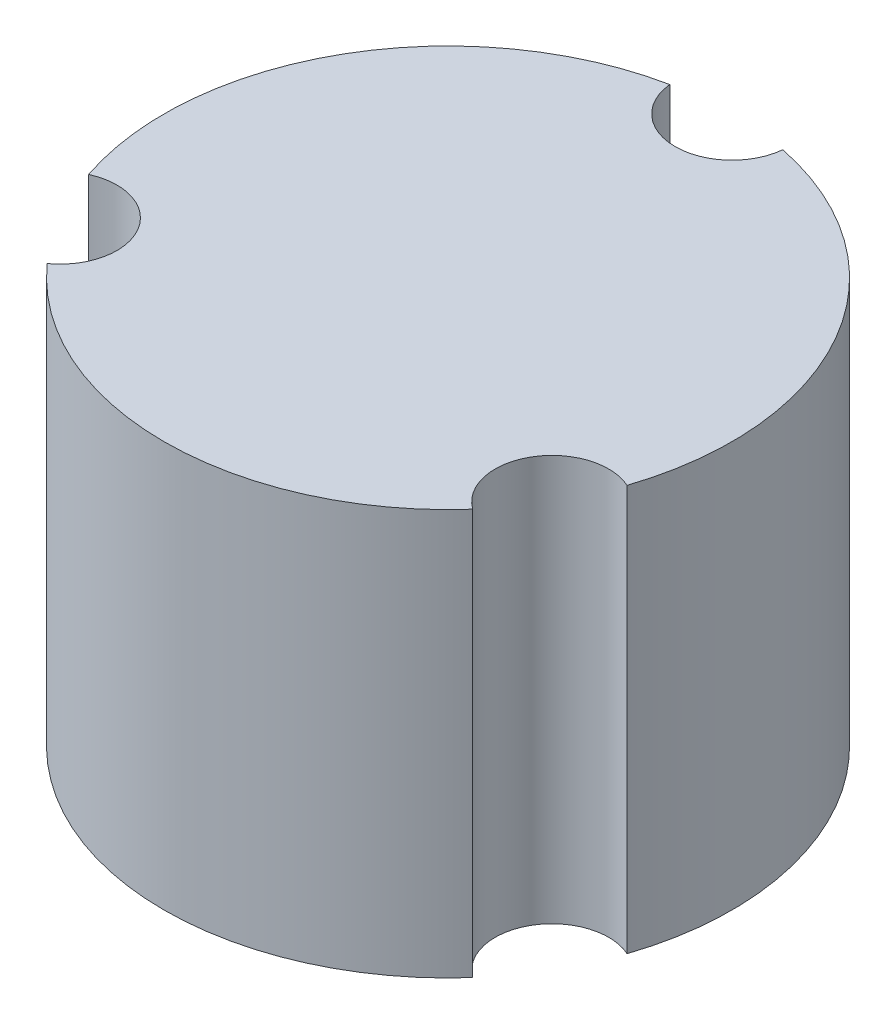
from build123d import *

# Parameters (mm, degrees)
CROQUIS1_R              = 22.225
SALIENTE_EXTRUIR1_DEPTH = 31.75
CROQUIS2_R              = 4.445
CORTAR_EXTRUIR1_DEPTH   = 32.75
VACIADO1_T              = -6.35


with BuildPart() as part:
    # Croquis1 → Saliente-Extruir1 (new body)
    with BuildSketch(Plane(origin=(0, 0, 0), x_dir=(1, 0, 0), z_dir=(0, 1, 0))):
        Circle(CROQUIS1_R)
    extrude(amount=SALIENTE_EXTRUIR1_DEPTH)

    # Croquis2 → Cortar-Extruir1 (cut, through all)
    with BuildSketch(Plane(origin=(0, 31.75, 0), x_dir=(1, 0, 0), z_dir=(0, 1, 0))):
        with Locations((0, 22.225)):
            Circle(CROQUIS2_R)
        with Locations((19.247414599, -11.1125)):
            Circle(CROQUIS2_R)
        with Locations((-19.247414599, -11.1125)):
            Circle(CROQUIS2_R)
    extrude(amount=-CORTAR_EXTRUIR1_DEPTH, mode=Mode.SUBTRACT)

    # Vaciado1
    vaciado1_openings = [part.faces().sort_by_distance(p)[0] for p in [
        (0, 0, 0),
    ]]
    offset(amount=VACIADO1_T, openings=vaciado1_openings, kind=Kind.INTERSECTION)


solid = part.part
